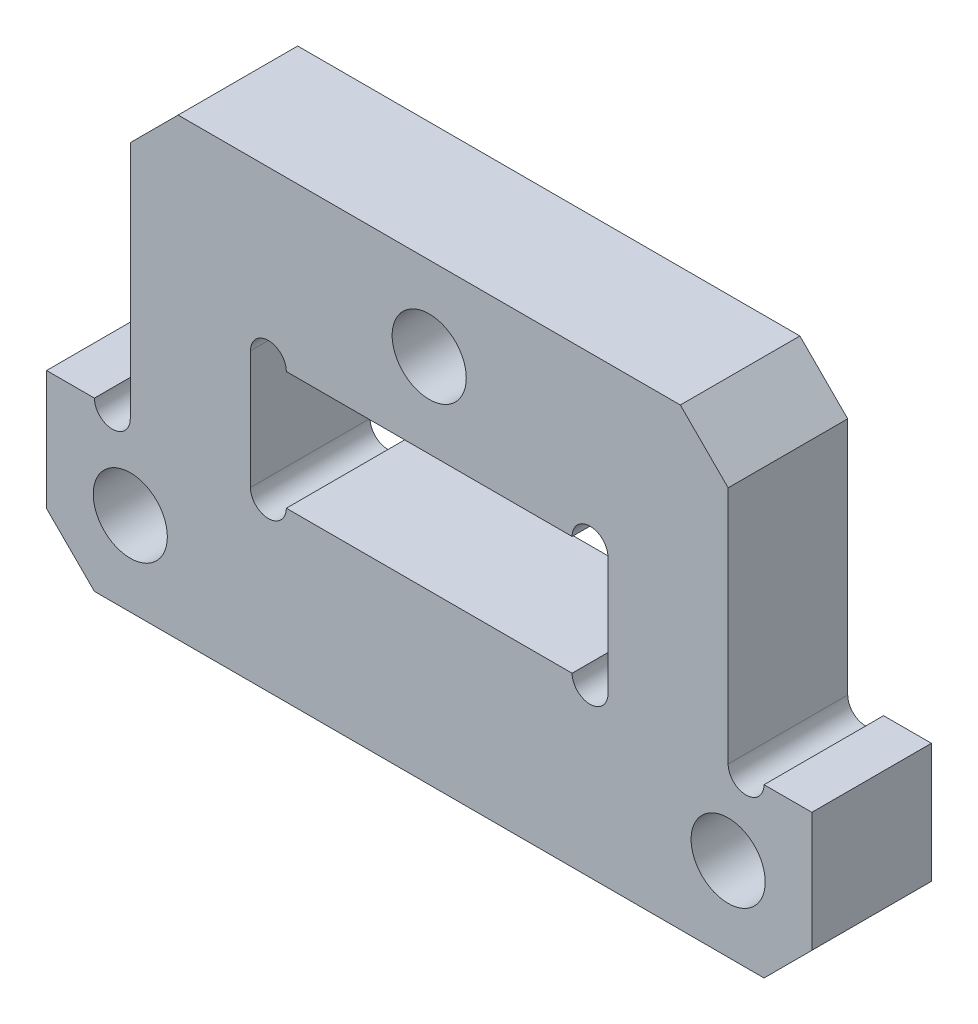
from build123d import *

# Parameters (mm, degrees)
SKETCH_1_R          = 1.55
SKETCH_1_W          = 14.95
SKETCH_1_H          = 4.95
EXTRUDE_1_DEPTH     = 2.5
SKETCH_2_R          = 0.75
CUT_EXTRUDE_1_DEPTH = 6
CHAMFER_1_SIZE      = 2


with BuildPart() as part:
    # 草图1 → 凸台-拉伸1 (new body, symmetric)
    with BuildSketch(Plane.XY):
        Polygon((-16, -2.5), (-16, -9.5), (16, -9.5), (16, -2.5), (12.5, -2.5), (12.5, 9.5), (-12.5, 9.5), (-12.5, -2.5), align=None)
        with Locations((-12.5, -6)):
            Circle(SKETCH_1_R, mode=Mode.SUBTRACT)
        with Locations((12.5, -6)):
            Circle(SKETCH_1_R, mode=Mode.SUBTRACT)
        with Locations((0, 6)):
            Circle(SKETCH_1_R, mode=Mode.SUBTRACT)
        Rectangle(SKETCH_1_W, SKETCH_1_H, mode=Mode.SUBTRACT)
    extrude(amount=EXTRUDE_1_DEPTH, both=True)

    # 草图2 → 切除-拉伸1 (cut, through all)
    with BuildSketch(Plane.XY.offset(2.5)):
        with Locations((-13.25, -2.5)):
            Circle(SKETCH_2_R)
        with Locations((-6.725, -2.475)):
            Circle(SKETCH_2_R)
        with Locations((-6.725, 2.475)):
            Circle(SKETCH_2_R)
        with Locations((6.725, 2.475)):
            Circle(SKETCH_2_R)
        with Locations((6.725, -2.475)):
            Circle(SKETCH_2_R)
        with Locations((13.25, -2.5)):
            Circle(SKETCH_2_R)
    extrude(amount=-CUT_EXTRUDE_1_DEPTH, mode=Mode.SUBTRACT)

    # 倒角1
    chamfer_1_edges = [part.edges().sort_by_distance(p)[0] for p in [
        (-16, -9.5, 0),
        (-12.5, 9.5, 0),
        (12.5, 9.5, 0),
        (16, -9.5, 0),
    ]]
    chamfer(chamfer_1_edges, length=CHAMFER_1_SIZE)


solid = part.part
